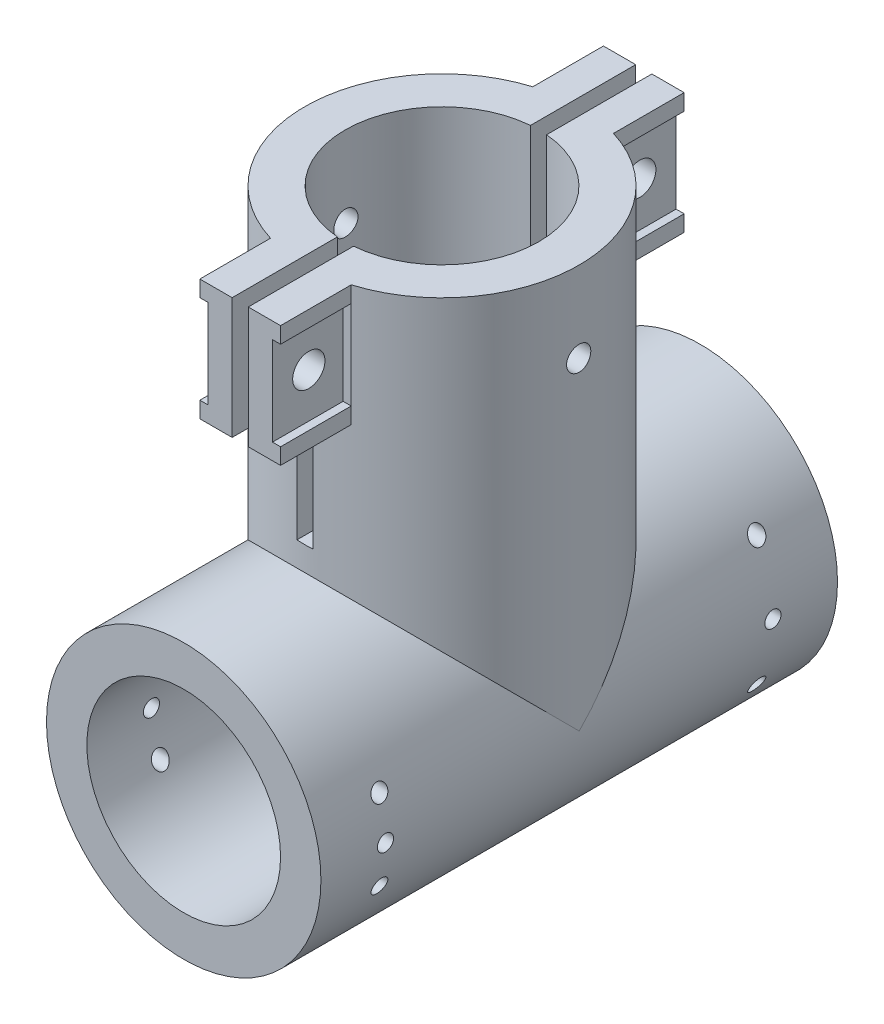
from build123d import *

# Parameters (mm, degrees)
SKETCH1_R             = 17
SKETCH1_R_2           = 12
BOSS_EXTRUDE1_DEPTH   = 64
SKETCH2_R             = 17
SKETCH2_R_2           = 12
BOSS_EXTRUDE2_DEPTH   = 50
SKETCH3_R             = 12
CUT_EXTRUDE1_DEPTH    = 65.0000001
SKETCH4_W             = 10
SKETCH4_H             = 15
BOSS_EXTRUDE3_DEPTH   = 25
SKETCH5_W             = 2
SKETCH5_H             = 30
CUT_EXTRUDE2_DEPTH    = 50
SKETCH6_R             = 12
CUT_EXTRUDE3_DEPTH    = 50
SKETCH7_W             = 8.751923191
SKETCH7_H             = 11
KES_EKSTR_ZYON4_DEPTH = 1
SKETCH8_R             = 2
CUT_EXTRUDE5_DEPTH    = 22
SKETCH9_R             = 1
SKETCH9_R_2           = 1.5
CUT_EXTRUDE6_DEPTH    = 35
CUT_EXTRUDE7_DEPTH    = 1


with BuildPart() as part:
    # Sketch1 → Boss-Extrude1 (new body)
    with BuildSketch(Plane.XY):
        with Locations((-32.297070802, 4.423200443)):
            Circle(SKETCH1_R)
        with Locations((-32.297070802, 4.423200443)):
            Circle(SKETCH1_R_2, mode=Mode.SUBTRACT)
    extrude(amount=BOSS_EXTRUDE1_DEPTH)

    # Sketch2 → Boss-Extrude2 (add)
    with BuildSketch(Plane(origin=(0, 4.423200443, 0), x_dir=(1, 0, 0), z_dir=(0, 1, 0))):
        with Locations((-32.297070802, -32)):
            Circle(SKETCH2_R)
        with Locations((-32.297070802, -32)):
            Circle(SKETCH2_R_2, mode=Mode.SUBTRACT)
    extrude(amount=BOSS_EXTRUDE2_DEPTH)

    # Sketch3 → Cut-Extrude1 (cut, through all)
    with BuildSketch(Plane.XY.offset(64)):
        with Locations((-32.297070802, 4.423200443)):
            Circle(SKETCH3_R)
    extrude(amount=-CUT_EXTRUDE1_DEPTH, mode=Mode.SUBTRACT)

    # Sketch4 → Boss-Extrude3 (add, symmetric)
    with BuildSketch(Plane(origin=(0, 0, 32), x_dir=(-1, 0, 0), z_dir=(0, 0, -1))):
        with Locations((32.297070802, 46.923200443)):
            Rectangle(SKETCH4_W, SKETCH4_H)
    extrude(amount=BOSS_EXTRUDE3_DEPTH, both=True)

    # Sketch5 → Cut-Extrude2 (cut)
    with BuildSketch(Plane.XY.offset(57)):
        with Locations((-32.297070802, 39.423200443)):
            Rectangle(SKETCH5_W, SKETCH5_H)
    extrude(amount=-CUT_EXTRUDE2_DEPTH, mode=Mode.SUBTRACT)

    # Sketch6 → Cut-Extrude3 (cut)
    with BuildSketch(Plane(origin=(0, 54.423200443, 0), x_dir=(1, 0, 0), z_dir=(0, 1, 0))):
        with Locations((-32.297070802, -32)):
            Circle(SKETCH6_R)
    extrude(amount=-CUT_EXTRUDE3_DEPTH, mode=Mode.SUBTRACT)

    # Sketch7 → Kes-Ekstr_zyon4 (cut)
    with BuildSketch(Plane(origin=(-27.297070802, 0, 0), x_dir=(0, 0, -1), z_dir=(1, 0, 0))):
        with Locations((-52.624038404, 46.923200443)):
            Rectangle(SKETCH7_W, SKETCH7_H)
        with Locations((-11.375961596, 46.923200443)):
            Rectangle(SKETCH7_W, SKETCH7_H)
    extrude(amount=-KES_EKSTR_ZYON4_DEPTH, mode=Mode.SUBTRACT)

    # Sketch8 → Cut-Extrude5 (cut, through all)
    with BuildSketch(Plane(origin=(-28.297070802, 0, 0), x_dir=(0, 0, -1), z_dir=(1, 0, 0))):
        with Locations((-52.5, 46.923200443)):
            Circle(SKETCH8_R)
        with Locations((-11.5, 46.923200443)):
            Circle(SKETCH8_R)
    extrude(amount=-CUT_EXTRUDE5_DEPTH, mode=Mode.SUBTRACT)

    # Sketch9 → Cut-Extrude6 (cut, through all)
    with BuildSketch(Plane(origin=(-15.297070802, 0, 0), x_dir=(0, 0, -1), z_dir=(1, 0, 0))):
        with Locations((-56, 4.423200443)):
            Circle(SKETCH9_R)
        with Locations((-56, 9.423200443)):
            Circle(SKETCH9_R)
        with Locations((-56, -0.576799557)):
            Circle(SKETCH9_R)
        with Locations((-8, 4.423200443)):
            Circle(SKETCH9_R)
        with Locations((-8, 12.423200443)):
            Circle(SKETCH9_R)
        with Locations((-8, -3.576799557)):
            Circle(SKETCH9_R)
        with Locations((-32, 44.423200443)):
            Circle(SKETCH9_R_2)
    extrude(amount=-CUT_EXTRUDE6_DEPTH, mode=Mode.SUBTRACT)

    # Sketch10 → Cut-Extrude7 (cut)
    with BuildSketch(Plane.ZY.offset(37.297070802)):
        Polygon((15.751923191, 51.423200443), (9.751923191, 51.423200443), (9.751923191, 50.099737278), (11.5, 51.108989895), (15.125, 49.016095169), (15.125, 44.830305717), (11.5, 42.737410991), (9.751923191, 43.746663608), (9.751923191, 42.423200443), (15.751923191, 42.423200443), (15.751923191, 41.423200443), (7, 41.423200443), (7, 42.423200443), (7, 51.423200443), (7, 52.423200443), (15.751923191, 52.423200443), align=None)
        Polygon((48.248076809, 42.423200443), (48.248076809, 41.423200443), (57, 41.423200443), (57, 42.423200443), (57, 51.423200443), (57, 52.423200443), (48.248076809, 52.423200443), (48.248076809, 51.423200443), (54.248076809, 51.423200443), (54.248076809, 50.099737278), (52.5, 51.108989895), (48.875, 49.016095169), (48.875, 44.830305717), (52.5, 42.737410991), (54.248076809, 43.746663608), (54.248076809, 42.423200443), align=None)
    extrude(amount=-CUT_EXTRUDE7_DEPTH, mode=Mode.SUBTRACT)


solid = part.part
